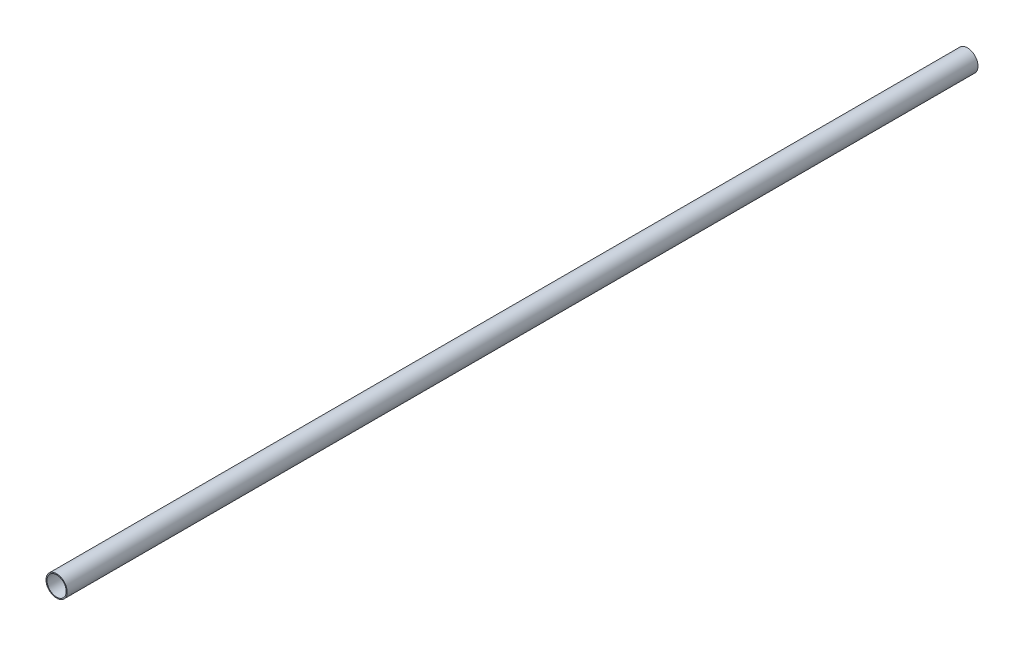
from build123d import *

# Parameters (mm, degrees)
SKETCH1_R           = 11
SKETCH1_R_2         = 10
BOSS_EXTRUDE1_DEPTH = 944


with BuildPart() as part:
    # Sketch1 → Boss-Extrude1 (new body)
    with BuildSketch(Plane.XY):
        Circle(SKETCH1_R)
        Circle(SKETCH1_R_2, mode=Mode.SUBTRACT)
    extrude(amount=BOSS_EXTRUDE1_DEPTH)


solid = part.part
